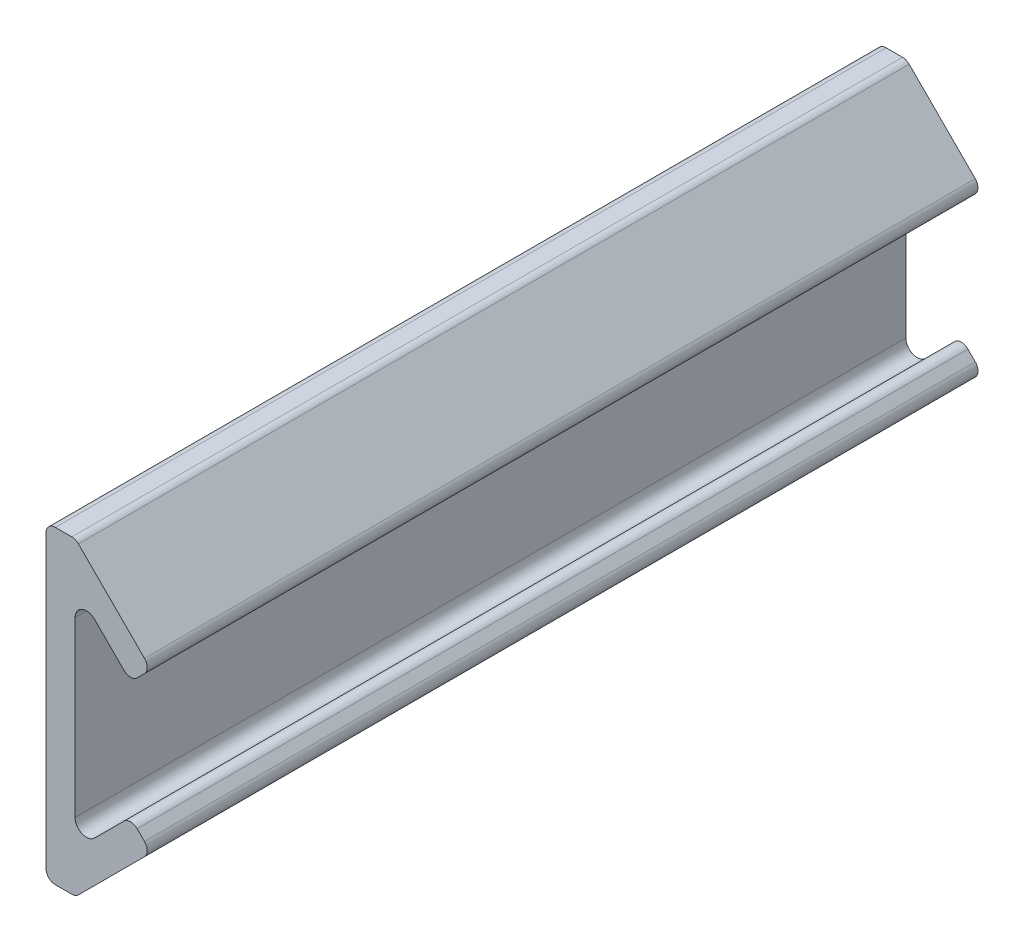
from build123d import *

# Parameters (mm, degrees)
BOSS_EXTRU_1_DEPTH = 80


with BuildPart() as part:
    # Esquisse1 → Boss.-Extru.1 (new body)
    with BuildSketch(Plane.XY):
        with BuildLine():
            Line((2.9, 0), (0.1, 0))
            Line((0.1, 0), (0.1, -14))
            ThreePointArc((0.1, -14), (0.363603897, -14.636396103), (1, -14.9))
            Line((1, -14.9), (2.585786438, -14.9))
            ThreePointArc((2.585786438, -14.9), (2.930201527, -14.831491579), (3.222182541, -14.636396103))
            Line((3.222182541, -14.636396103), (9.586143571, -8.272435072))
            ThreePointArc((9.586143571, -8.272435072), (9.849747468, -7.636038969), (9.586143571, -6.999642866))
            Line((9.586143571, -6.999642866), (8.87903679, -6.292536085))
            ThreePointArc((8.87903679, -6.292536085), (8.242640687, -6.028932188), (7.606244584, -6.292536085))
            Line((7.606244584, -6.292536085), (4.777817459, -9.12096321))
            ThreePointArc((4.777817459, -9.12096321), (3.579048224, -9.359413236), (2.9, -8.343145751))
            Line((2.9, -8.343145751), (2.9, 0))
        make_face()
        with BuildLine():
            Line((0.1, 14), (0.1, 0))
            Line((0.1, 0), (2.9, 0))
            Line((2.9, 0), (2.9, 8.343145751))
            ThreePointArc((2.9, 8.343145751), (3.579048224, 9.359413236), (4.777817459, 9.12096321))
            Line((4.777817459, 9.12096321), (7.606244584, 6.292536085))
            ThreePointArc((7.606244584, 6.292536085), (8.242640687, 6.028932188), (8.87903679, 6.292536085))
            Line((8.87903679, 6.292536085), (9.586143571, 6.999642866))
            ThreePointArc((9.586143571, 6.999642866), (9.849747468, 7.636038969), (9.586143571, 8.272435072))
            Line((9.586143571, 8.272435072), (3.222182541, 14.636396103))
            ThreePointArc((3.222182541, 14.636396103), (2.930201527, 14.831491579), (2.585786438, 14.9))
            Line((2.585786438, 14.9), (1, 14.9))
            ThreePointArc((1, 14.9), (0.363603897, 14.636396103), (0.1, 14))
        make_face()
    extrude(amount=BOSS_EXTRU_1_DEPTH)


solid = part.part
